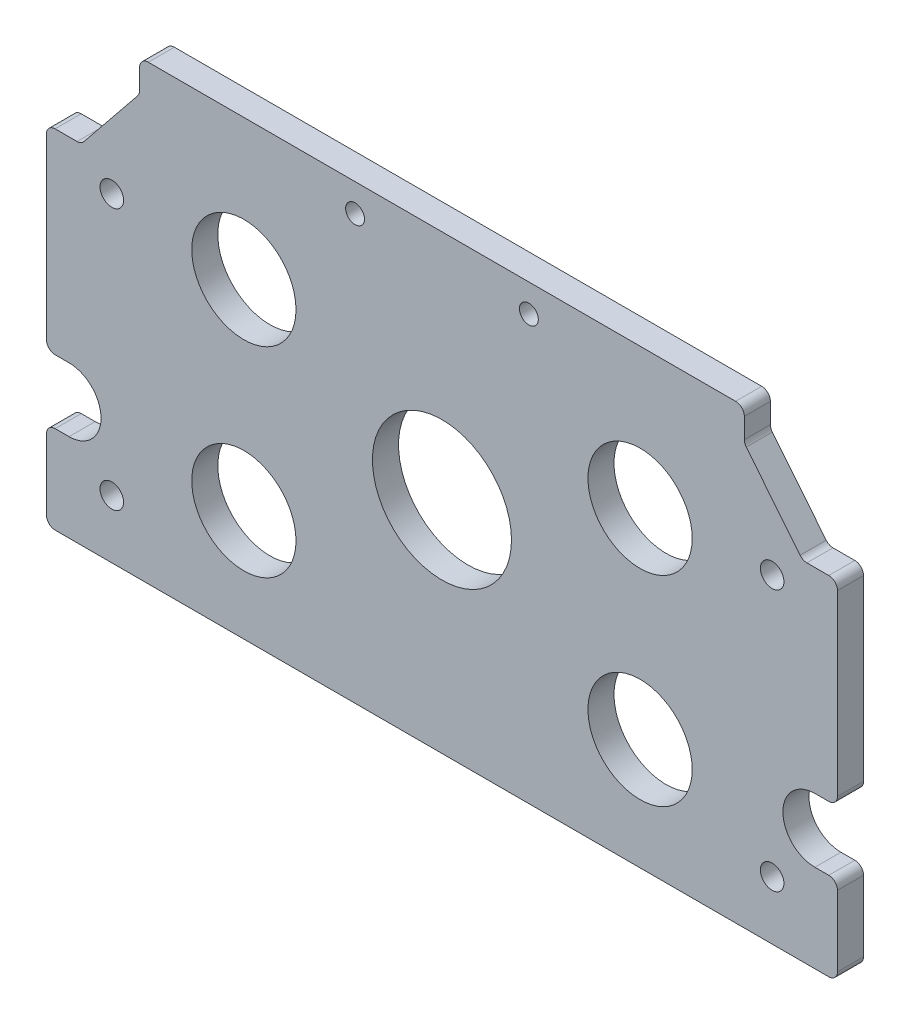
from build123d import *

# Parameters (mm, degrees)
BOSS_EXTRUDE1_DEPTH         = 4.7625
F_6_CLEARANCE_HOLE1_D       = 4.3053
F_3_4_0_75_DIAMETER_HOLE1_D = 19.05
F_1_1_DIAMETER_HOLE1_D      = 25.4
F_4_CLEARANCE_HOLE1_D       = 3.4544


with BuildPart() as part:
    # Sketch1 → Boss-Extrude1 (new body)
    with BuildSketch(Plane.XY):
        with BuildLine():
            Line((0.762, 54.483), (0.762, 41.5925))
            ThreePointArc((0.762, 41.5925), (1.226967985, 40.469967985), (2.3495, 40.005))
            Line((2.3495, 40.005), (143.7005, 40.005))
            ThreePointArc((143.7005, 40.005), (144.823032015, 40.469967985), (145.288, 41.5925))
            Line((145.288, 41.5925), (145.288, 54.483))
            ThreePointArc((145.288, 54.483), (144.823032015, 55.605532015), (143.7005, 56.0705))
            Line((143.7005, 56.0705), (141.1605, 56.0705))
            ThreePointArc((141.1605, 56.0705), (135.3185, 61.9125), (141.1605, 67.7545))
            Line((141.1605, 67.7545), (143.7005, 67.7545))
            ThreePointArc((143.7005, 67.7545), (144.823032015, 68.219467985), (145.288, 69.342))
            Line((145.288, 69.342), (145.288, 101.9175))
            ThreePointArc((145.288, 101.9175), (144.823032015, 103.040032015), (143.7005, 103.505))
            Line((143.7005, 103.505), (139.696431174, 103.505))
            ThreePointArc((139.696431174, 103.505), (139.012088949, 103.660078285), (138.46144955, 104.095014842))
            Line((138.46144955, 104.095014842), (128.622518376, 116.276548677))
            ThreePointArc((128.622518376, 116.276548677), (128.360721864, 116.745061754), (128.27, 117.274033834))
            Line((128.27, 117.274033834), (128.27, 120.9675))
            ThreePointArc((128.27, 120.9675), (127.805032015, 122.090032015), (126.6825, 122.555))
            Line((126.6825, 122.555), (19.3675, 122.555))
            ThreePointArc((19.3675, 122.555), (18.244967985, 122.090032015), (17.78, 120.9675))
            Line((17.78, 120.9675), (17.78, 117.274033834))
            ThreePointArc((17.78, 117.274033834), (17.689278136, 116.745061754), (17.427481624, 116.276548677))
            Line((17.427481624, 116.276548677), (7.58855045, 104.095014842))
            ThreePointArc((7.58855045, 104.095014842), (7.037911051, 103.660078285), (6.353568826, 103.505))
            Line((6.353568826, 103.505), (2.3495, 103.505))
            ThreePointArc((2.3495, 103.505), (1.226967985, 103.040032015), (0.762, 101.9175))
            Line((0.762, 101.9175), (0.762, 69.342))
            ThreePointArc((0.762, 69.342), (1.226967985, 68.219467985), (2.3495, 67.7545))
            Line((2.3495, 67.7545), (4.8895, 67.7545))
            ThreePointArc((4.8895, 67.7545), (10.7315, 61.9125), (4.8895, 56.0705))
            Line((4.8895, 56.0705), (2.3495, 56.0705))
            ThreePointArc((2.3495, 56.0705), (1.226967985, 55.605532015), (0.762, 54.483))
        make_face()
    extrude(amount=BOSS_EXTRUDE1_DEPTH)

    # #6 Clearance Hole1 (through all)
    with Locations(Plane.XY.offset(4.7625)):
        with Locations((12.7, 98.425), (133.35, 98.425), (133.35, 50.673), (12.7, 50.673)):
            Hole(F_6_CLEARANCE_HOLE1_D / 2)

    # 3/4 (0.75) Diameter Hole1 (through all)
    with Locations(Plane.XY.offset(4.7625)):
        with Locations((36.83, 96.901), (109.22, 96.901), (109.22, 60.325), (36.83, 60.325)):
            Hole(F_3_4_0_75_DIAMETER_HOLE1_D / 2)

    # 1 (1) Diameter Hole1 (through all)
    with Locations(Plane.XY.offset(4.7625)):
        with Locations((73.025, 80.137)):
            Hole(F_1_1_DIAMETER_HOLE1_D / 2)

    # #4 Clearance Hole1 (through all)
    with Locations(Plane.XY.offset(4.7625)):
        with Locations((57.15, 117.475), (88.9, 117.475)):
            Hole(F_4_CLEARANCE_HOLE1_D / 2)


solid = part.part
